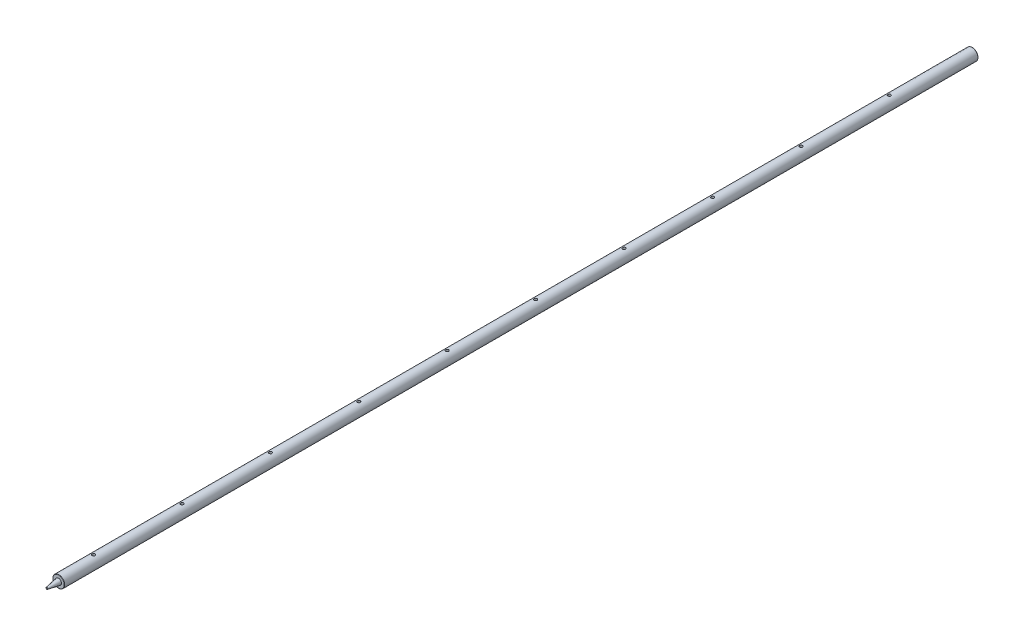
from build123d import *

# Parameters (mm, degrees)
FILLET1_R           = 0.508
LPATTERN1_COUNT     = 8
LPATTERN1_PITCH     = 150
LPATTERN1_COL_COUNT = 3
LPATTERN1_COL_PITCH = 150


with BuildPart() as part:
    # Sketch1 → Revolve1 (revolve)
    with BuildSketch(Plane(origin=(0, 0, 0), x_dir=(1, 0, 0), z_dir=(0, 1, 0)), mode=Mode.PRIVATE) as revolve1_sk:
        Polygon((0, 1550), (0, -20), (1.473460386, -20), (5, 0), (10, 0), (10, 1550), align=None)
    revolve(revolve1_sk.sketch.rotate(Axis((0, 0, -1550), (0, 0, 1)), 180), axis=Axis((0, 0, -1550), (0, 0, 1)))  # turned: the seam where the file's is

    # Fillet1
    fillet1_edges = [part.edges().sort_by_distance(p)[0] for p in [
        (10, 0, -1550),
        (10, 0, 0),
        (1.473460386, 0, 20),
    ]]
    fillet(fillet1_edges, radius=FILLET1_R)

    # Sketch3 → M6x1.0 Tapped Hole1 (revolve, cut)
    with BuildSketch(Plane(origin=(0, 10, -1109.22499992), x_dir=(0, 0, 1), z_dir=(1, 0, 0))):
        Polygon((0, 0), (0, 16.502151548), (2.5, 15), (2.5, 0), align=None)
    m6x1_0_tapped_hole1 = revolve(axis=Axis((0, 16.35, -1109.22499992), (0, -1, 0)), mode=Mode.SUBTRACT)

    # LPattern1: M6x1.0 Tapped Hole1 ×8
    with Locations(*[(0, 0, i * LPATTERN1_PITCH) for i in range(1, LPATTERN1_COUNT)]):
        add(m6x1_0_tapped_hole1, mode=Mode.SUBTRACT)

    # LPattern1 col: M6x1.0 Tapped Hole1 ×3
    with Locations(*[(0, 0, -i * LPATTERN1_COL_PITCH) for i in range(1, LPATTERN1_COL_COUNT)]):
        add(m6x1_0_tapped_hole1, mode=Mode.SUBTRACT)


solid = part.part
